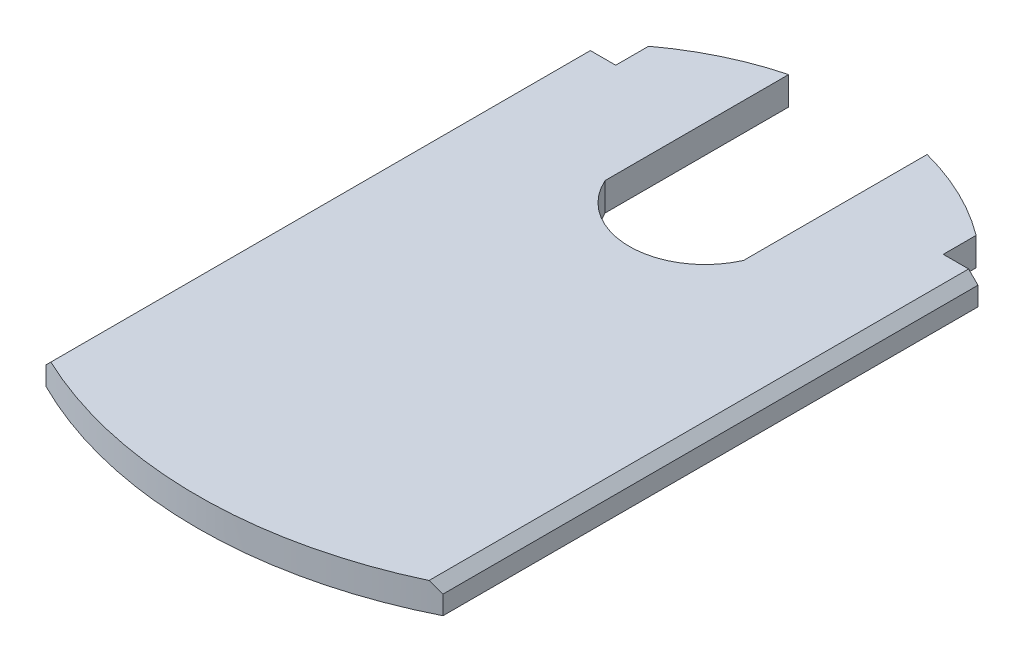
from build123d import *

# Parameters (mm, degrees)
BOSS_EXTRUDE1_DEPTH = 3
CUT_EXTRUDE1_DEPTH  = 3
CHAMFER1_SIZE       = 1


with BuildPart() as part:
    # Sketch1 → Boss-Extrude1 (new body)
    with BuildSketch(Plane(origin=(0, 0, 0), x_dir=(1, 0, 0), z_dir=(0, 1, 0))):
        with BuildLine():
            Line((-21.15, 28.5), (-21.15, -28.5))
            ThreePointArc((-21.15, -28.5), (0, -33.5), (21.15, -28.5))
            Line((21.15, -28.5), (21.15, 28.5))
            Line((21.15, 28.5), (-21.15, 28.5))
        make_face()
        with BuildLine():
            Line((-17.45, 32), (-17.45, 28.5))
            Line((-17.45, 28.5), (17.45, 28.5))
            Line((17.45, 28.5), (17.45, 32))
            ThreePointArc((17.45, 32), (0, 37.8), (-17.45, 32))
        make_face()
    extrude(amount=BOSS_EXTRUDE1_DEPTH)

    # Sketch2 → Cut-Extrude1 (cut)
    with BuildSketch(Plane(origin=(0, 3, 0), x_dir=(1, 0, 0), z_dir=(0, 1, 0))):
        with BuildLine():
            Line((-7.375, 17.3), (-7.375, 37.8))
            Line((-7.375, 37.8), (7.375, 37.8))
            Line((7.375, 37.8), (7.375, 17.3))
            ThreePointArc((7.375, 17.3), (0, 12.5), (-7.375, 17.3))
        make_face()
    extrude(amount=-CUT_EXTRUDE1_DEPTH, mode=Mode.SUBTRACT)

    # Chamfer1
    chamfer1_edges = [part.edges().sort_by_distance(p)[0] for p in [
        (21.15, 3, 0),
        (-21.15, 3, 0),
    ]]
    chamfer(chamfer1_edges, length=CHAMFER1_SIZE)


solid = part.part
